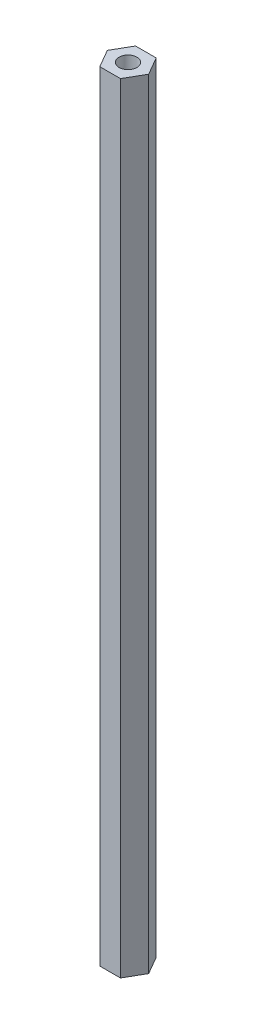
from build123d import *

# Parameters (mm, degrees)
BOSS_EXTRUDE1_DEPTH = 152.4
SKETCH2_R           = 1.75
CUT_EXTRUDE1_DEPTH  = 2000


with BuildPart() as part:
    # Sketch1 → Boss-Extrude1 (new body)
    with BuildSketch(Plane(origin=(0, 0, 0), x_dir=(1, 0, 0), z_dir=(0, 1, 0))):
        Polygon((-2.020725942, 3.5), (-4.041451884, 0), (-2.020725942, -3.5), (2.020725942, -3.5), (4.041451884, 0), (2.020725942, 3.5), align=None)
    extrude(amount=BOSS_EXTRUDE1_DEPTH)

    # Sketch2 → Cut-Extrude1 (cut)
    with BuildSketch(Plane(origin=(0, 152.4, 0), x_dir=(1, 0, 0), z_dir=(0, 1, 0))):
        Circle(SKETCH2_R)
    extrude(amount=-CUT_EXTRUDE1_DEPTH, mode=Mode.SUBTRACT)


solid = part.part
